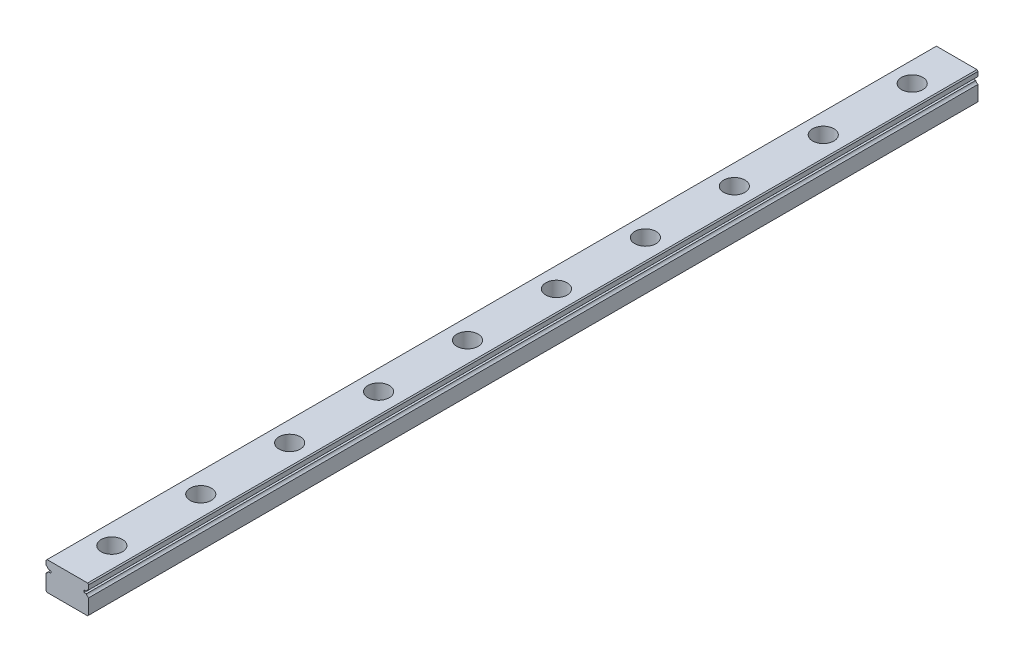
from build123d import *

# Parameters (mm, degrees)
EXTRUDE_1_DEPTH        = 250
SKETCH_2_R             = 3
SKETCH_2_R_2           = 1.75
CUT_EXTRUDE_1_DEPTH    = 4.5
SKETCH_2_2_R           = 1.75
CUT_EXTRUDE_2_DEPTH    = 251.199920064
PATTERN_LINEAR_1_COUNT = 10
PATTERN_LINEAR_1_PITCH = 25


with BuildPart() as part:
    # Эскиз1 → Бобышка-Вытянуть1 (new body)
    with BuildSketch(Plane.XY):
        with BuildLine():
            Line((-6, 3.7), (-5.7, 4))
            Line((-5.7, 4), (5.7, 4))
            Line((5.7, 4), (6, 3.7))
            Line((6, 3.7), (6, 2.451013544))
            ThreePointArc((6, 2.451013544), (5.597935912, 2.202976267), (5.354599002, 1.798050138))
            Line((5.354599002, 1.798050138), (4.643514056, 1.798050138))
            Line((4.643514056, 1.798050138), (4.643514056, 1.201949862))
            Line((4.643514056, 1.201949862), (5.354599002, 1.201949862))
            ThreePointArc((5.354599002, 1.201949862), (5.597935912, 0.797023733), (6, 0.548986456))
            Line((6, 0.548986456), (6, -3.7))
            Line((6, -3.7), (5.7, -4))
            Line((5.7, -4), (-5.7, -4))
            Line((-5.7, -4), (-6, -3.7))
            Line((-6, -3.7), (-6, 0.548986456))
            ThreePointArc((-6, 0.548986456), (-5.597935912, 0.797023733), (-5.354599002, 1.201949862))
            Line((-5.354599002, 1.201949862), (-4.643514056, 1.201949862))
            Line((-4.643514056, 1.201949862), (-4.643514056, 1.798050138))
            Line((-4.643514056, 1.798050138), (-5.354599002, 1.798050138))
            ThreePointArc((-5.354599002, 1.798050138), (-5.597935912, 2.202976267), (-6, 2.451013544))
            Line((-6, 2.451013544), (-6, 3.7))
        make_face()
    extrude(amount=EXTRUDE_1_DEPTH)

    # Эскиз2 → Вырез-Вытянуть1 (cut)
    with BuildSketch(Plane(origin=(0, 4, 0), x_dir=(1, 0, 0), z_dir=(0, 1, 0))):
        with Locations((0, -12.5)):
            Circle(SKETCH_2_R)
        with Locations((0, -12.5)):
            Circle(SKETCH_2_R_2, mode=Mode.SUBTRACT)
    cut_extrude_1 = extrude(amount=-CUT_EXTRUDE_1_DEPTH, mode=Mode.SUBTRACT)

    # Эскиз2<2> → Вырез-Вытянуть2 (cut, through all)
    with BuildSketch(Plane(origin=(0, 4, 0), x_dir=(1, 0, 0), z_dir=(0, 1, 0))):
        with Locations((0, -12.5)):
            Circle(SKETCH_2_2_R)
    cut_extrude_2 = extrude(amount=-CUT_EXTRUDE_2_DEPTH, mode=Mode.SUBTRACT)

    # Линейный массив1: Вырез-Вытянуть1, Вырез-Вытянуть2 ×10
    with Locations(*[(0, 0, i * PATTERN_LINEAR_1_PITCH) for i in range(1, PATTERN_LINEAR_1_COUNT)]):
        add(cut_extrude_1, mode=Mode.SUBTRACT)
        add(cut_extrude_2, mode=Mode.SUBTRACT)


solid = part.part
